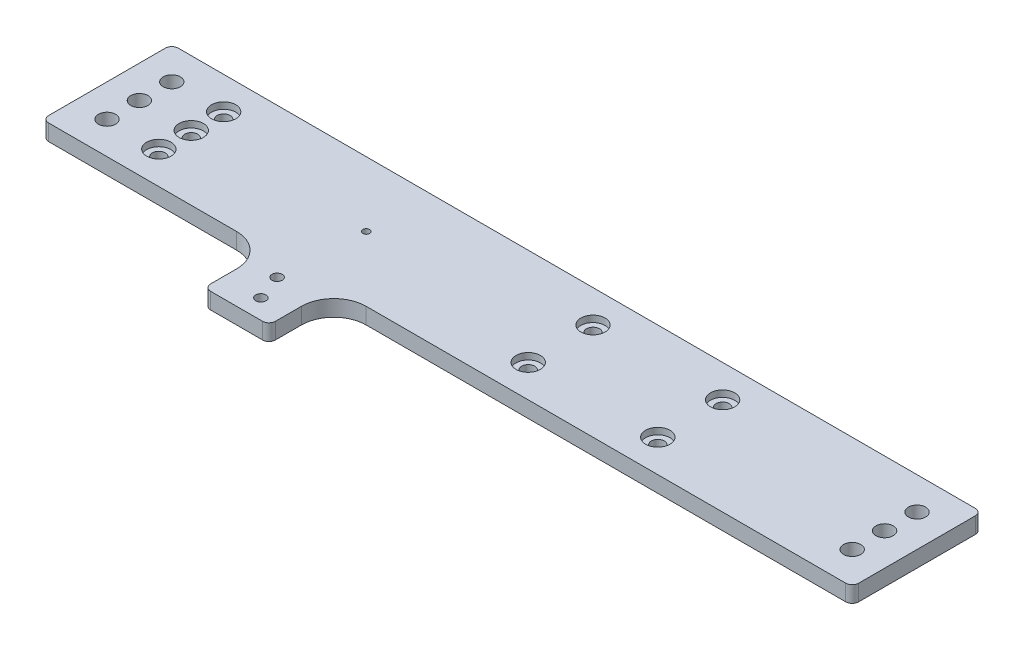
from build123d import *

# Parameters (mm, degrees)
SKETCH1_W                                       = 317.5
SKETCH1_H                                       = 50.8
BOSS_EXTRUDE1_DEPTH                             = 6.35
CBORE_FOR_10_SOCKET_HEAD_CAP_SCREW1_D           = 5.1054
CBORE_FOR_10_SOCKET_HEAD_CAP_SCREW1_CBORE_D     = 9.525
CBORE_FOR_10_SOCKET_HEAD_CAP_SCREW1_CBORE_DEPTH = 2.54
F_1_4_CLEARANCE_HOLE2_D                         = 6.7564
F_6_32_TAPPED_HOLE1_D                           = 2.7051
SKETCH12_W                                      = 25.4
SKETCH12_H                                      = 25.4
BOSS_EXTRUDE3_DEPTH                             = 6.35
F_10_32_TAPPED_HOLE1_D                          = 4.0386
FILLET1_R                                       = 12.7
FILLET2_R                                       = 2.54


with BuildPart() as part:
    # Sketch1 → Boss-Extrude1 (new body)
    with BuildSketch(Plane(origin=(0, 0, 0), x_dir=(1, 0, 0), z_dir=(0, 1, 0))):
        Rectangle(SKETCH1_W, SKETCH1_H)
    extrude(amount=BOSS_EXTRUDE1_DEPTH)

    # CBORE for #10 Socket Head Cap Screw1 (through all)
    with Locations(Plane(origin=(0, 6.35, 0), x_dir=(1, 0, 0), z_dir=(0, 1, 0))):
        with Locations((-125.73, -12.7), (19.05, 12.7), (69.85, 12.7), (19.05, -12.7), (69.85, -12.7), (-125.73, 12.7), (-125.73, 0)):
            CounterBoreHole(CBORE_FOR_10_SOCKET_HEAD_CAP_SCREW1_D / 2, CBORE_FOR_10_SOCKET_HEAD_CAP_SCREW1_CBORE_D / 2, CBORE_FOR_10_SOCKET_HEAD_CAP_SCREW1_CBORE_DEPTH)

    # 1/4 Clearance Hole2 (through all)
    with Locations(Plane.XZ):
        with Locations((-146.05, 12.7), (-146.05, 0), (-146.05, -12.7), (146.05, 12.7), (146.05, 0), (146.05, -12.7)):
            Hole(F_1_4_CLEARANCE_HOLE2_D / 2)

    # #6-32 Tapped Hole1 (through all)
    with Locations(Plane(origin=(0, 0, 0), x_dir=(-1, 0, 0), z_dir=(0, -1, 0))):
        with Locations((57.15, 0)):
            Hole(F_6_32_TAPPED_HOLE1_D / 2)

    # Sketch12 → Boss-Extrude3 (add)
    with BuildSketch(Plane(origin=(0, 6.35, 0), x_dir=(1, 0, 0), z_dir=(0, 1, 0))):
        with Locations((-57.15, -38.1)):
            Rectangle(SKETCH12_W, SKETCH12_H)
    extrude(amount=-BOSS_EXTRUDE3_DEPTH)

    # #10-32 Tapped Hole1 (through all)
    with Locations(Plane(origin=(0, 0, 0), x_dir=(-1, 0, 0), z_dir=(0, -1, 0))):
        with Locations((55.245, -43.18), (59.055, -33.02)):
            Hole(F_10_32_TAPPED_HOLE1_D / 2)

    # Fillet1
    fillet1_edges = [part.edges().sort_by_distance(p)[0] for p in [
        (-44.45, 3.175, 25.4),
        (-69.85, 3.175, 25.4),
    ]]
    fillet(fillet1_edges, radius=FILLET1_R)

    # Fillet2
    fillet2_edges = [part.edges().sort_by_distance(p)[0] for p in [
        (-44.45, 3.175, 50.8),
        (-69.85, 3.175, 50.8),
        (158.75, 3.175, 25.4),
        (-158.75, 3.175, 25.4),
        (-158.75, 3.175, -25.4),
        (158.75, 3.175, -25.4),
    ]]
    fillet(fillet2_edges, radius=FILLET2_R)


solid = part.part
